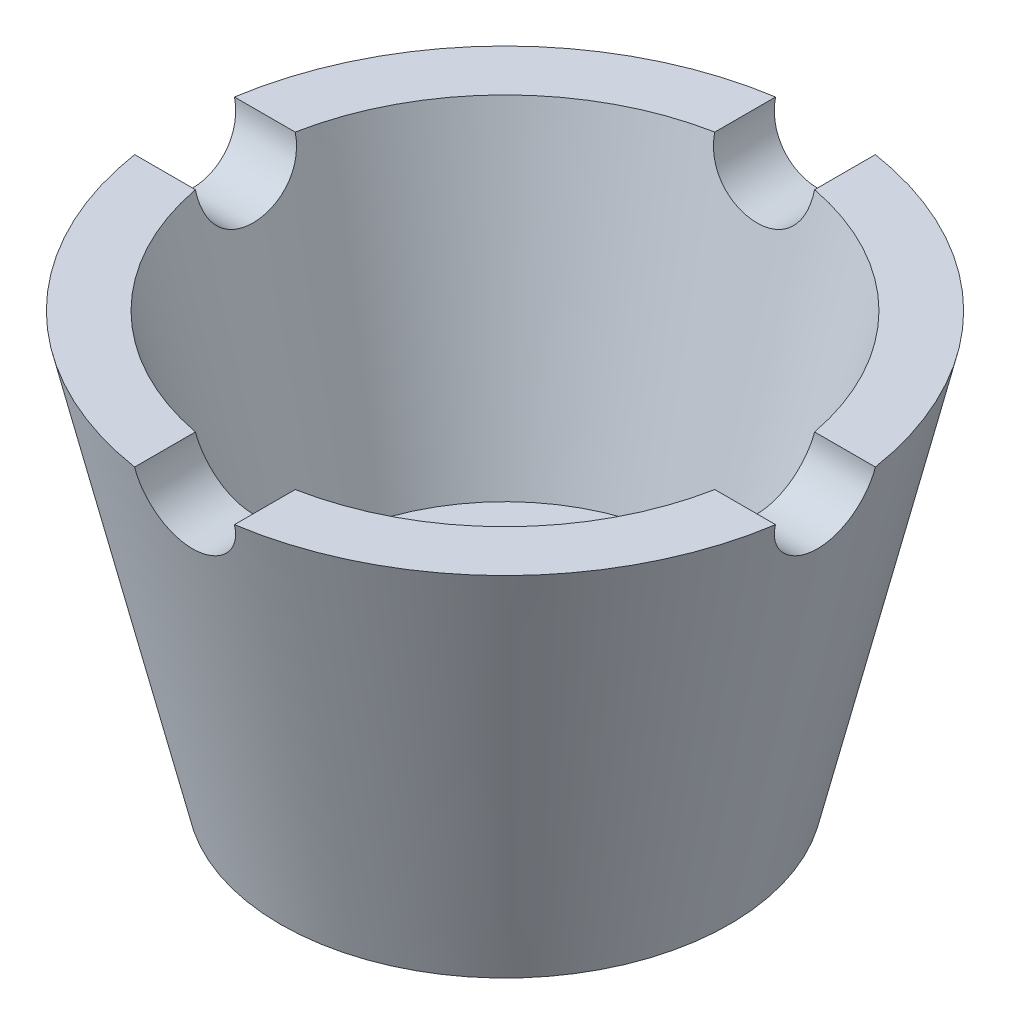
from build123d import *

# Parameters (mm, degrees)
SKETCH2_R          = 5
CUT_EXTRUDE1_DEPTH = 56
CIRPATTERN1_COUNT  = 4


with BuildPart() as part:
    # Sketch1 → Revolve1 (revolve)
    with BuildSketch(Plane.XY):
        Polygon((11.25, -75.117525247), (22.5, -75.117525247), (32.5, -33.117525247), (26.5, -33.117525247), (19, -63.117525247), (11, -63.117525247), align=None)
    revolve(axis=Axis((0, 54.787552818, 0), (0, -1, 0)))

    # Sketch2 → Cut-Extrude1 (cut)
    with BuildSketch(Plane.XY):
        with Locations((0, -33.117525247)):
            Circle(SKETCH2_R)
    cut_extrude1 = extrude(amount=-CUT_EXTRUDE1_DEPTH, mode=Mode.SUBTRACT)

    # CirPattern1: Cut-Extrude1 ×4 about axis
    cirpattern1_axis = Axis((0, -63.117525247, 0), (0, -1, 0))
    for i in range(1, CIRPATTERN1_COUNT):
        add(cut_extrude1.rotate(cirpattern1_axis, i * 360 / CIRPATTERN1_COUNT), mode=Mode.SUBTRACT)


solid = part.part
